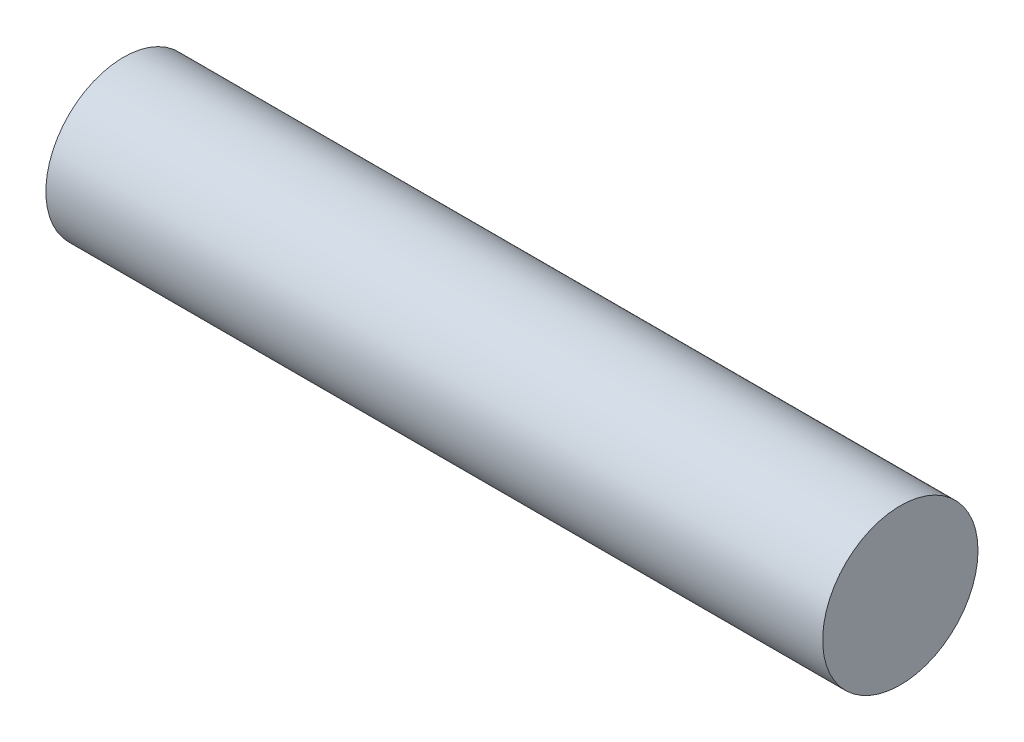
from build123d import *

# Parameters (mm, degrees)
SKETCH1_R           = 1
BOSS_EXTRUDE1_DEPTH = 10


with BuildPart() as part:
    # Sketch1 → Boss-Extrude1 (new body)
    with BuildSketch(Plane(origin=(0, 0, 0), x_dir=(0, 0, -1), z_dir=(1, 0, 0))):
        Circle(SKETCH1_R)
    extrude(amount=BOSS_EXTRUDE1_DEPTH)


solid = part.part
